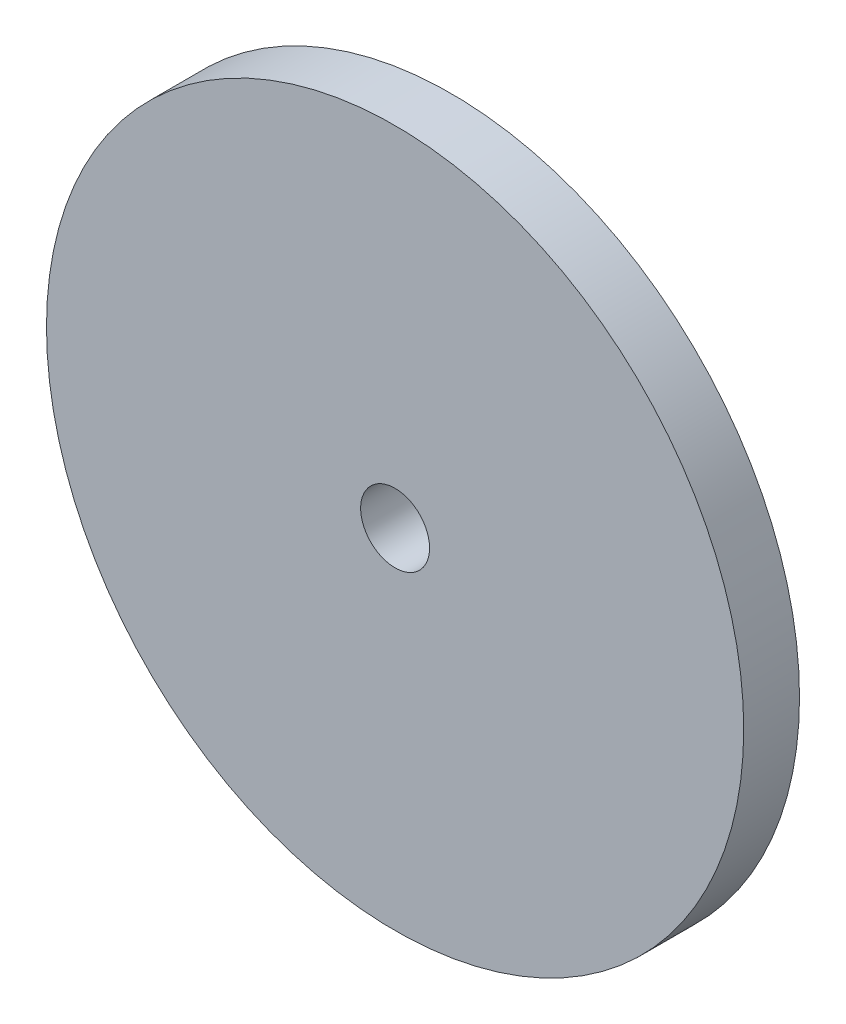
from build123d import *

# Parameters (mm, degrees)
SKETCH1_W = 5.08
SKETCH1_H = 28.6131


with BuildPart() as part:
    # Sketch1 → Revolve1 (revolve)
    with BuildSketch(Plane(origin=(0, 0, 0), x_dir=(0, 0, -1), z_dir=(1, 0, 0))):
        with Locations((2.54, 17.44345)):
            Rectangle(SKETCH1_W, SKETCH1_H)
    revolve(axis=Axis((0, 0, 0), (0, 0, -1)))


solid = part.part
